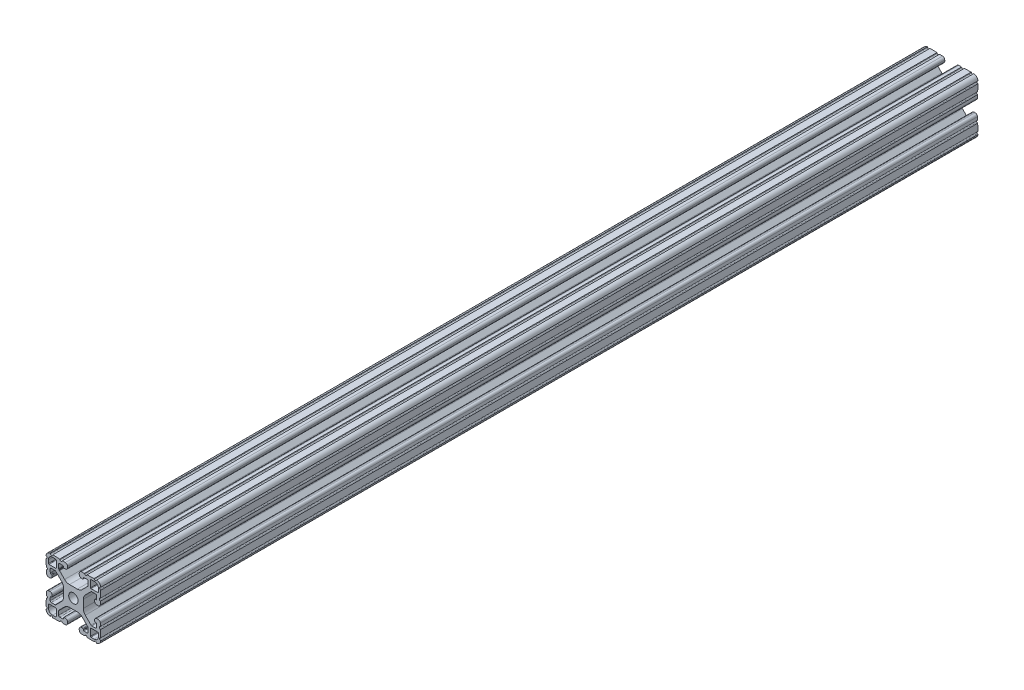
from build123d import *

# Parameters (mm, degrees)
BOSS_EXTRUDE1_DEPTH     = 304.8
CUT_EXTRUDE2_DEPTH      = 305.8
CUT_EXTRUDE2_DEPTH_BACK = 305.8
CUT_EXTRUDE1_DEPTH      = 305.8
CUT_EXTRUDE1_DEPTH_BACK = 305.8


with BuildPart() as part:
    # Sketch4 → Boss-Extrude1 (new body, symmetric)
    with BuildSketch(Plane.XY):
        with BuildLine():
            Line((15.764194098, -19.048065876), (5.596097049, -18.692988103))
            ThreePointArc((5.596097049, -18.692988103), (4.509548067, -18.209225328), (4.064, -17.106455165))
            Line((4.064, -17.106455165), (4.064, -16.343990692))
            ThreePointArc((4.064, -16.343990692), (4.548729837, -15.202038759), (5.706902951, -14.757457754))
            Line((5.706902951, -14.757457754), (6.490296708, -14.784814467))
            ThreePointArc((6.490296708, -14.784814467), (6.751068464, -14.900917533), (6.858, -15.165582372))
            Line((6.858, -15.165582372), (6.858, -15.689138401))
            ThreePointArc((6.858, -15.689138401), (6.964931536, -15.95380324), (7.225703292, -16.069906306))
            Line((7.225703292, -16.069906306), (9.465548524, -16.148123425))
            ThreePointArc((9.465548524, -16.148123425), (10.044635082, -15.925832923), (10.287, -15.354856956))
            Line((10.287, -15.354856956), (10.287, -12.771043484))
            ThreePointArc((10.287, -12.771043484), (10.226579379, -12.46728851), (10.054516008, -12.209777477))
            Line((10.054516008, -12.209777477), (6.093922742, -8.249184211))
            ThreePointArc((6.093922742, -8.249184211), (4.552976719, -7.219556996), (2.735306952, -6.858))
            Line((2.735306952, -6.858), (0, -6.858))
            Line((0, -6.858), (0, -3.2639))
            ThreePointArc((0, -3.2639), (2.307925823, -2.307925823), (3.2639, 0))
            Line((3.2639, 0), (6.858, 0))
            Line((6.858, 0), (6.858, -2.735306952))
            ThreePointArc((6.858, -2.735306952), (7.219556996, -4.552976719), (8.249184211, -6.093922742))
            Line((8.249184211, -6.093922742), (12.209777477, -10.054516008))
            ThreePointArc((12.209777477, -10.054516008), (12.46728851, -10.226579379), (12.771043484, -10.287))
            Line((12.771043484, -10.287), (15.354856956, -10.287))
            ThreePointArc((15.354856956, -10.287), (15.925832923, -10.044635082), (16.148123425, -9.465548524))
            Line((16.148123425, -9.465548524), (16.069906306, -7.225703292))
            ThreePointArc((16.069906306, -7.225703292), (15.95380324, -6.964931536), (15.689138401, -6.858))
            Line((15.689138401, -6.858), (15.165582372, -6.858))
            ThreePointArc((15.165582372, -6.858), (14.900917533, -6.751068464), (14.784814467, -6.490296708))
            Line((14.784814467, -6.490296708), (14.757457754, -5.706902951))
            ThreePointArc((14.757457754, -5.706902951), (15.202038759, -4.548729837), (16.343990692, -4.064))
            Line((16.343990692, -4.064), (17.106455165, -4.064))
            ThreePointArc((17.106455165, -4.064), (18.209225328, -4.509548067), (18.692988103, -5.596097049))
            Line((18.692988103, -5.596097049), (19.048065876, -15.764194098))
            ThreePointArc((19.048065876, -15.764194098), (18.12006403, -18.12006403), (15.764194098, -19.048065876))
        make_face()
        with BuildLine():
            Line((11.8872, -12.2682), (11.8872, -16.943575443))
            ThreePointArc((11.8872, -16.943575443), (11.994131536, -17.208240282), (12.254903292, -17.324343348))
            Line((12.254903292, -17.324343348), (14.445350862, -17.400835462))
            ThreePointArc((14.445350862, -17.400835462), (16.565633801, -16.565633801), (17.400835462, -14.445350862))
            Line((17.400835462, -14.445350862), (17.324343348, -12.254903292))
            ThreePointArc((17.324343348, -12.254903292), (17.208240282, -11.994131536), (16.943575443, -11.8872))
            Line((16.943575443, -11.8872), (12.2682, -11.8872))
            ThreePointArc((12.2682, -11.8872), (11.998792316, -11.998792316), (11.8872, -12.2682))
        make_face(mode=Mode.SUBTRACT)
    extrude(amount=BOSS_EXTRUDE1_DEPTH, both=True)

    # Sketch8 → Cut-Extrude2 (cut, two sides)
    with BuildSketch(Plane.XY) as cut_extrude2_sk:
        with BuildLine():
            Line((7.649186899, -18.76468358), (9.495813101, -18.829169188))
            Line((9.495813101, -18.829169188), (9.278946369, -18.421302187))
            ThreePointArc((9.278946369, -18.421302187), (8.600423087, -17.997313783), (7.893976718, -18.372937981))
            Line((7.893976718, -18.372937981), (7.649186899, -18.76468358))
        make_face()
        with BuildLine():
            Line((14.316686899, -18.997517811), (16.163313101, -19.062003418))
            Line((16.163313101, -19.062003418), (15.946446369, -18.654136417))
            ThreePointArc((15.946446369, -18.654136417), (15.267923087, -18.230148014), (14.561476718, -18.605772211))
            Line((14.561476718, -18.605772211), (14.316686899, -18.997517811))
        make_face()
        with BuildLine():
            Line((18.605772211, -14.561476718), (18.997517811, -14.316686899))
            Line((18.997517811, -14.316686899), (19.062003418, -16.163313101))
            Line((19.062003418, -16.163313101), (18.654136417, -15.946446369))
            ThreePointArc((18.654136417, -15.946446369), (18.230148014, -15.267923087), (18.605772211, -14.561476718))
        make_face()
        with BuildLine():
            Line((18.372937981, -7.893976718), (18.76468358, -7.649186899))
            Line((18.76468358, -7.649186899), (18.829169188, -9.495813101))
            Line((18.829169188, -9.495813101), (18.421302187, -9.278946369))
            ThreePointArc((18.421302187, -9.278946369), (17.997313783, -8.600423087), (18.372937981, -7.893976718))
        make_face()
    extrude(amount=CUT_EXTRUDE2_DEPTH, mode=Mode.SUBTRACT)
    extrude(cut_extrude2_sk.sketch, amount=-CUT_EXTRUDE2_DEPTH_BACK, mode=Mode.SUBTRACT)

    # Mirror1: part across plane


with BuildPart() as part_1:
    add(part.part)
    add(part.part.mirror(Plane(origin=(0, 0, 0), x_dir=(0, 0, 1), z_dir=(1, 0, 0))))

    # Mirror2: part across plane


with BuildPart() as part_2:
    add(part_1.part)
    add(part_1.part.mirror(Plane.ZX))

    # Sketch5 → Cut-Extrude1 (cut, two sides)
    with BuildSketch(Plane.XY) as cut_extrude1_sk:
        with BuildLine():
            Line((-10.133783723, 12.50797511), (-10.133783723, 11.99997511))
            ThreePointArc((-10.133783723, 11.99997511), (-10.084187138, 11.880238362), (-9.964450389, 11.830641777))
            Line((-9.964450389, 11.830641777), (-9.650582015, 11.830641777))
            Line((-9.650582015, 11.830641777), (-9.650582015, 12.50797511))
            Line((-9.650582015, 12.50797511), (-10.133783723, 12.50797511))
        make_face()
    extrude(amount=CUT_EXTRUDE1_DEPTH, mode=Mode.SUBTRACT)
    extrude(cut_extrude1_sk.sketch, amount=-CUT_EXTRUDE1_DEPTH_BACK, mode=Mode.SUBTRACT)


solid = part_2.part
